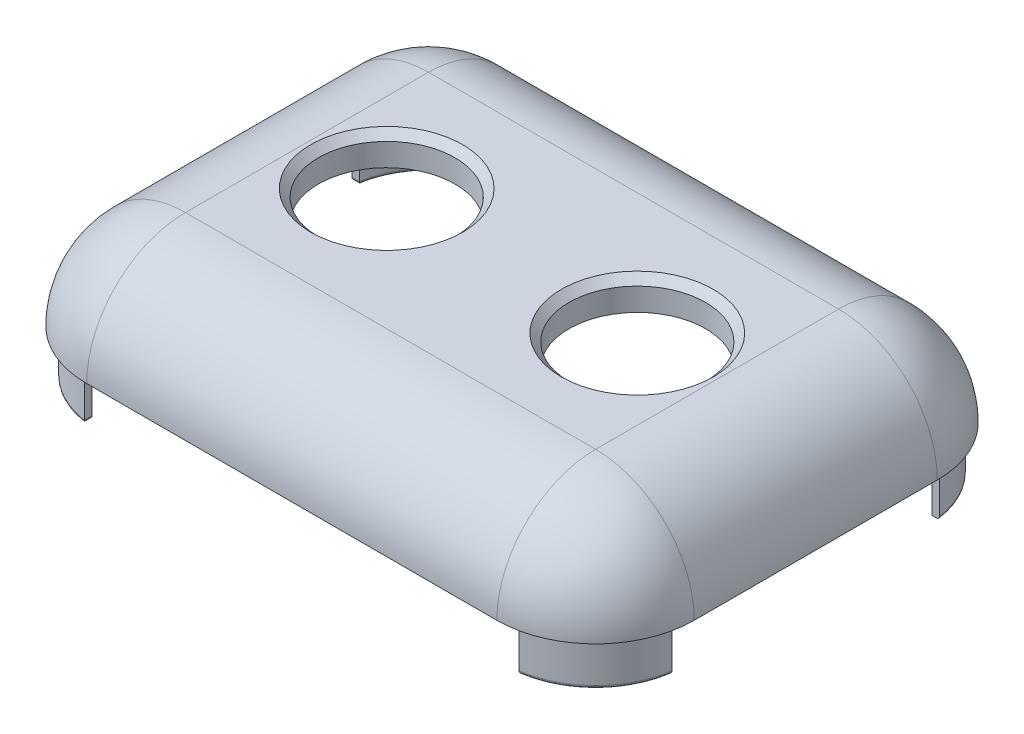
from build123d import *

# Parameters (mm, degrees)
SKETCH1_W           = 40
SKETCH1_H           = 29
BOSS_EXTRUDE1_DEPTH = 20
FILLET2_R           = 6.5
SKETCH3_W           = 48.982601016
SKETCH3_H           = 39.309165856
CUT_EXTRUDE1_DEPTH  = 14.5
SHELL1_T            = -2
BOSS_EXTRUDE3_DEPTH = 3
FILLET3_R           = 0.2
SKETCH6_R           = 4.5
CUT_EXTRUDE2_DEPTH  = 10.5000001
CHAMFER1_SIZE       = 0.5


with BuildPart() as part:
    # Sketch1 → Boss-Extrude1 (new body)
    with BuildSketch(Plane(origin=(0, 0, 0), x_dir=(1, 0, 0), z_dir=(0, 1, 0))):
        Rectangle(SKETCH1_W, SKETCH1_H)
    extrude(amount=BOSS_EXTRUDE1_DEPTH)

    # Fillet2
    fillet2_edges = [part.edges().sort_by_distance(p)[0] for p in [
        (-20, 20, 0),
        (0, 20, 14.5),
        (20, 20, 0),
        (0, 0, 14.5),
        (-20, 0, 0),
        (0, 0, -14.5),
        (20, 0, 0),
        (20, 10, 14.5),
        (-20, 10, 14.5),
        (-20, 10, -14.5),
        (20, 10, -14.5),
        (0, 20, -14.5),
    ]]
    fillet(fillet2_edges, radius=FILLET2_R)

    # Sketch3 → Cut-Extrude1 (cut, through all)
    with BuildSketch(Plane(origin=(0, 13.5, 0), x_dir=(1, 0, 0), z_dir=(0, 1, 0))):
        Rectangle(SKETCH3_W, SKETCH3_H)
    extrude(amount=-CUT_EXTRUDE1_DEPTH, mode=Mode.SUBTRACT)

    # Shell1
    shell1_openings = [part.faces().sort_by_distance(p)[0] for p in [
        (0, 13.5, 0),
    ]]
    offset(amount=SHELL1_T, openings=shell1_openings)

    # Sketch5 → Boss-Extrude3 (add)
    with BuildSketch(Plane.XZ.offset(-13.5)):
        with BuildLine():
            Line((-14.3, 13.845511098), (-14.3, 13.340411969))
            ThreePointArc((-14.3, 13.340411969), (-17.318376618, 11.818376618), (-18.840411969, 8.8))
            Line((-18.840411969, 8.8), (-19.345511098, 8.8))
            ThreePointArc((-19.345511098, 8.8), (-17.671930009, 12.171930009), (-14.3, 13.845511098))
        make_face()
        with BuildLine():
            Line((-14.3, -13.845511098), (-14.3, -13.340411969))
            ThreePointArc((-14.3, -13.340411969), (-17.318376618, -11.818376618), (-18.840411969, -8.8))
            Line((-18.840411969, -8.8), (-19.345511098, -8.8))
            ThreePointArc((-19.345511098, -8.8), (-17.671930009, -12.171930009), (-14.3, -13.845511098))
        make_face()
        with BuildLine():
            Line((14.3, -13.845511098), (14.3, -13.340411969))
            ThreePointArc((14.3, -13.340411969), (17.318376618, -11.818376618), (18.840411969, -8.8))
            Line((18.840411969, -8.8), (19.345511098, -8.8))
            ThreePointArc((19.345511098, -8.8), (17.671930009, -12.171930009), (14.3, -13.845511098))
        make_face()
        with BuildLine():
            Line((19.345511098, 8.8), (18.840411969, 8.8))
            ThreePointArc((18.840411969, 8.8), (17.318376618, 11.818376618), (14.3, 13.340411969))
            Line((14.3, 13.340411969), (14.3, 13.845511098))
            ThreePointArc((14.3, 13.845511098), (17.671930009, 12.171930009), (19.345511098, 8.8))
        make_face()
    extrude(amount=BOSS_EXTRUDE3_DEPTH)

    # Fillet3
    fillet3_edges = [part.edges().sort_by_distance(p)[0] for p in [
        (-17.318376618, 10.5, 11.818376618),
        (-17.671930009, 10.5, 12.171930009),
        (-17.318376618, 10.5, -11.818376618),
        (-17.671930009, 10.5, -12.171930009),
        (17.318376618, 10.5, 11.818376618),
        (17.671930009, 10.5, 12.171930009),
        (17.671930009, 10.5, -12.171930009),
        (-14.3, 10.5, 13.592961534),
        (-19.092961534, 10.5, 8.8),
        (-19.092961534, 10.5, -8.8),
        (-14.3, 10.5, -13.592961534),
        (19.092961534, 10.5, 8.8),
        (14.3, 10.5, 13.592961534),
    ]]
    fillet(fillet3_edges, radius=FILLET3_R)

    # Sketch6 → Cut-Extrude2 (cut, through all)
    with BuildSketch(Plane(origin=(0, 20, 0), x_dir=(1, 0, 0), z_dir=(0, 1, 0))):
        with Locations(Location((-8.25, 0, 0), (0, 0, 270))):  # turned: the seam where the file's is
            Circle(SKETCH6_R)
        with Locations(Location((8.25, 0, 0), (0, 0, 270))):  # turned: the seam where the file's is
            Circle(SKETCH6_R)
    extrude(amount=-CUT_EXTRUDE2_DEPTH, mode=Mode.SUBTRACT)

    # Chamfer1
    chamfer1_edges = [part.edges().sort_by_distance(p)[0] for p in [
        (-8.25, 20, -4.5),
        (8.25, 20, -4.5),
    ]]
    chamfer(chamfer1_edges, length=CHAMFER1_SIZE)


solid = part.part
